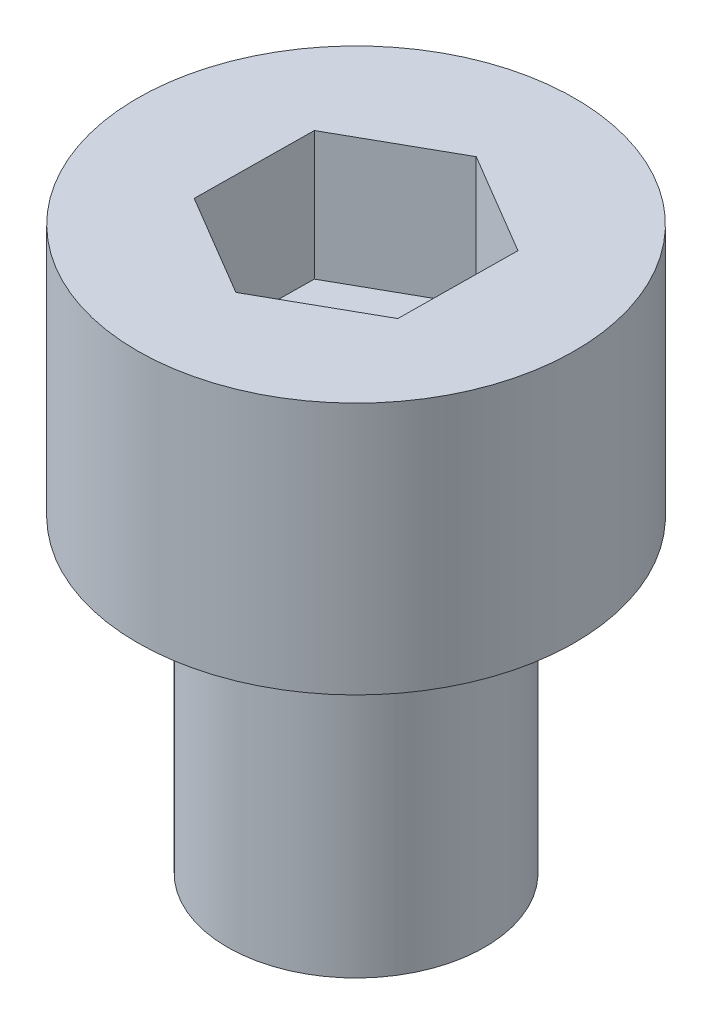
from build123d import *

# Parameters (mm, degrees)
SKETCH_1_R          = 2.5
EXTRUDE_1_DEPTH     = 6
SKETCH_2_R          = 4.25
EXTRUDE_2_DEPTH     = 4.91
CUT_EXTRUDE_1_DEPTH = 2.5


with BuildPart() as part:
    # 草图1 → 凸台-拉伸1 (new body)
    with BuildSketch(Plane(origin=(0, 0, 0), x_dir=(1, 0, 0), z_dir=(0, 1, 0))):
        Circle(SKETCH_1_R)
    extrude(amount=EXTRUDE_1_DEPTH)

    # 草图2 → 凸台-拉伸2 (add)
    with BuildSketch(Plane(origin=(0, 6, 0), x_dir=(1, 0, 0), z_dir=(0, 1, 0))):
        Circle(SKETCH_2_R)
    extrude(amount=EXTRUDE_2_DEPTH)

    # 草图3 → 切除-拉伸1 (cut)
    with BuildSketch(Plane(origin=(0, 10.91, 0), x_dir=(1, 0, 0), z_dir=(0, 1, 0))):
        Polygon((1.987239819, -1.176525067), (2.012520506, 1.132737633), (0.025280687, 2.309262701), (-1.987239819, 1.176525067), (-2.012520506, -1.132737633), (-0.025280687, -2.309262701), align=None)
    extrude(amount=-CUT_EXTRUDE_1_DEPTH, mode=Mode.SUBTRACT)


solid = part.part
